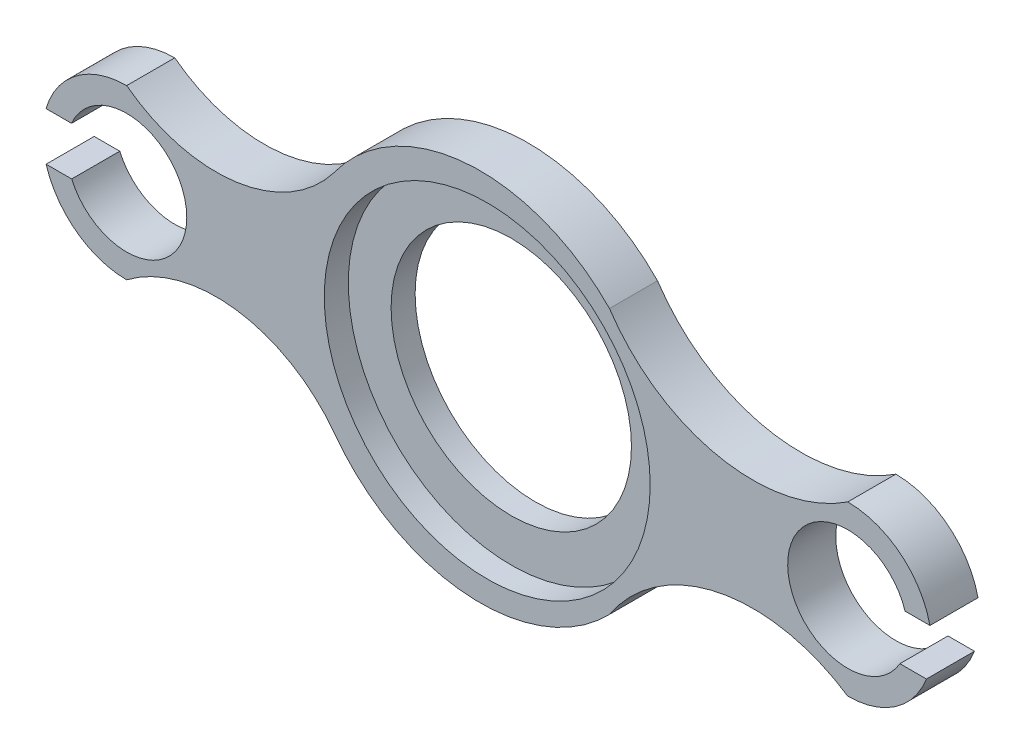
from build123d import *

# Parameters (mm, degrees)
SKETCH1_R           = 67.8
SKETCH1_R_2         = 50
BOSS_EXTRUDE1_DEPTH = 10
SKETCH2_R           = 25
BOSS_EXTRUDE2_DEPTH = 20
SKETCH3_R           = 67.8
CUT_EXTRUDE1_DEPTH  = 10
SKETCH4_R           = 50
CUT_EXTRUDE2_DEPTH  = 11
SKETCH5_W           = 15.080994576
SKETCH5_H           = 20
CUT_EXTRUDE3_DEPTH  = 21
SKETCH6_W           = 19.646297403
SKETCH6_H           = 20
CUT_EXTRUDE4_DEPTH  = 21


with BuildPart() as part:
    # Sketch1 → Boss-Extrude1 (new body)
    with BuildSketch(Plane.XY):
        Circle(SKETCH1_R)
        Circle(SKETCH1_R_2, mode=Mode.SUBTRACT)
    extrude(amount=BOSS_EXTRUDE1_DEPTH)

    # Sketch2 → Boss-Extrude2 (add)
    with BuildSketch(Plane.XY):
        with BuildLine():
            ThreePointArc((-63.772719488, 46.746532272), (-8.415408503, 77.65917808), (50.844425579, 55.113765796))
            ThreePointArc((50.844425579, 55.113765796), (96.256515498, 24.521091043), (150, 35))
            ThreePointArc((150, 35), (185, 0), (150, -35))
            ThreePointArc((150, -35), (96.256515498, -24.521091043), (50.844425579, -55.113765796))
            ThreePointArc((50.844425579, -55.113765796), (-8.415408503, -77.65917808), (-63.772719488, -46.746532272))
            ThreePointArc((-63.772719488, -46.746532272), (-104.453573255, -23.015011619), (-150, -35))
            ThreePointArc((-150, -35), (-185, 0), (-150, 35))
            ThreePointArc((-150, 35), (-104.453573255, 23.015011619), (-63.772719488, 46.746532272))
        make_face()
        with Locations((-150, 0)):
            Circle(SKETCH2_R, mode=Mode.SUBTRACT)
        with Locations((150, 0)):
            Circle(SKETCH2_R, mode=Mode.SUBTRACT)
    extrude(amount=BOSS_EXTRUDE2_DEPTH)

    # Sketch3 → Cut-Extrude1 (cut)
    with BuildSketch(Plane.XY.offset(20)):
        Circle(SKETCH3_R)
    extrude(amount=-CUT_EXTRUDE1_DEPTH, mode=Mode.SUBTRACT)

    # Sketch4 → Cut-Extrude2 (cut, through all)
    with BuildSketch(Plane.XY.offset(10)):
        Circle(SKETCH4_R)
    extrude(amount=-CUT_EXTRUDE2_DEPTH, mode=Mode.SUBTRACT)

    # Sketch5 → Cut-Extrude3 (cut, through all)
    with BuildSketch(Plane.XY.offset(20)):
        with Locations((-180.419979471, -0.076174623)):
            Rectangle(SKETCH5_W, SKETCH5_H)
    extrude(amount=-CUT_EXTRUDE3_DEPTH, mode=Mode.SUBTRACT)

    # Sketch6 → Cut-Extrude4 (cut, through all)
    with BuildSketch(Plane.XY.offset(20)):
        with Locations((179.499488159, -2.442655022)):
            Rectangle(SKETCH6_W, SKETCH6_H)
    extrude(amount=-CUT_EXTRUDE4_DEPTH, mode=Mode.SUBTRACT)


solid = part.part
